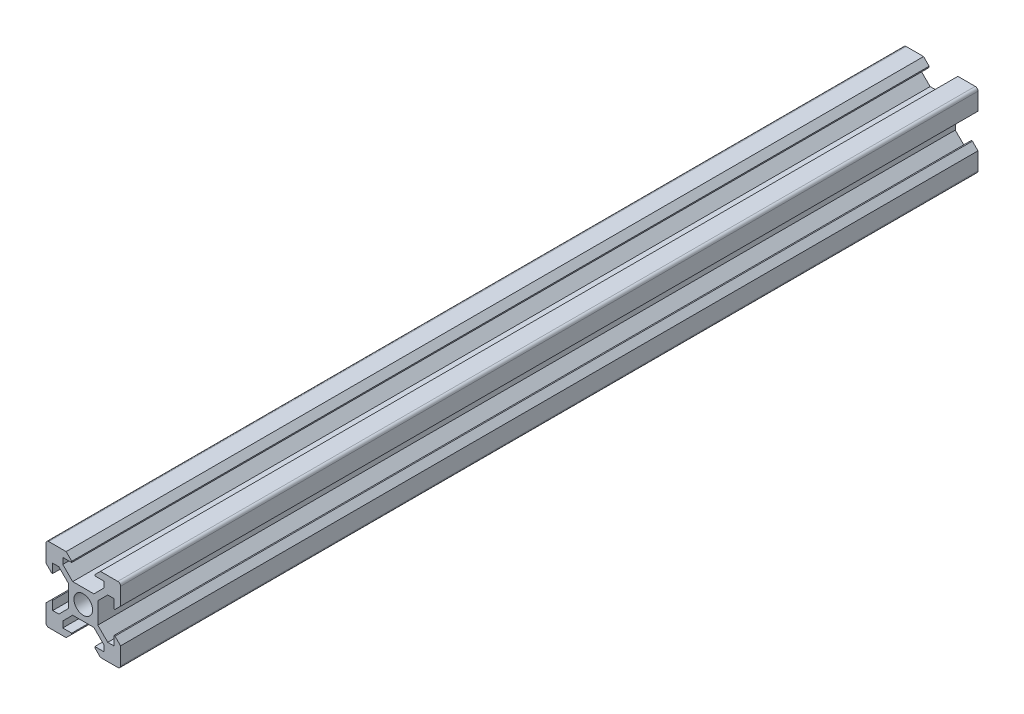
from build123d import *

# Parameters (mm, degrees)
CROQUIS1_R              = 2.5
SALIENTE_EXTRUIR1_DEPTH = 230


with BuildPart() as part:
    # Croquis1 → Saliente-Extruir1 (new body)
    with BuildSketch(Plane.XY):
        with BuildLine():
            Line((-4.6, 10), (-3.1, 8.5))
            Line((-3.1, 8.5), (-3.1, 8.2))
            Line((-3.1, 8.2), (-5.5, 8.2))
            Line((-5.5, 8.2), (-5.5, 6.560660172))
            Line((-5.5, 6.560660172), (-2.84, 3.900660172))
            Line((-2.84, 3.900660172), (0, 3.900660172))
            Line((0, 3.900660172), (2.84, 3.900660172))
            Line((2.84, 3.900660172), (5.5, 6.560660172))
            Line((5.5, 6.560660172), (5.5, 8.2))
            Line((5.5, 8.2), (3.1, 8.2))
            Line((3.1, 8.2), (3.1, 8.5))
            Line((3.1, 8.5), (4.6, 10))
            Line((4.6, 10), (9.25, 10))
            ThreePointArc((9.25, 10), (9.780330086, 9.780330086), (10, 9.25))
            Line((10, 9.25), (10, 4.6))
            Line((10, 4.6), (8.5, 3.1))
            Line((8.5, 3.1), (8.2, 3.1))
            Line((8.2, 3.1), (8.2, 5.5))
            Line((8.2, 5.5), (6.560660172, 5.5))
            Line((6.560660172, 5.5), (3.900660172, 2.84))
            Line((3.900660172, 2.84), (3.900660172, 0))
            Line((3.900660172, 0), (3.900660172, -2.84))
            Line((3.900660172, -2.84), (6.560660172, -5.5))
            Line((6.560660172, -5.5), (8.2, -5.5))
            Line((8.2, -5.5), (8.2, -3.1))
            Line((8.2, -3.1), (8.5, -3.1))
            Line((8.5, -3.1), (10, -4.6))
            Line((10, -4.6), (10, -9.25))
            ThreePointArc((10, -9.25), (9.780330086, -9.780330086), (9.25, -10))
            Line((9.25, -10), (4.6, -10))
            Line((4.6, -10), (3.1, -8.5))
            Line((3.1, -8.5), (3.1, -8.2))
            Line((3.1, -8.2), (5.5, -8.2))
            Line((5.5, -8.2), (5.5, -6.560660172))
            Line((5.5, -6.560660172), (2.84, -3.900660172))
            Line((2.84, -3.900660172), (0, -3.900660172))
            Line((0, -3.900660172), (-2.84, -3.900660172))
            Line((-2.84, -3.900660172), (-5.5, -6.560660172))
            Line((-5.5, -6.560660172), (-5.5, -8.2))
            Line((-5.5, -8.2), (-3.1, -8.2))
            Line((-3.1, -8.2), (-3.1, -8.5))
            Line((-3.1, -8.5), (-4.6, -10))
            Line((-4.6, -10), (-9.25, -10))
            ThreePointArc((-9.25, -10), (-9.780330086, -9.780330086), (-10, -9.25))
            Line((-10, -9.25), (-10, -4.6))
            Line((-10, -4.6), (-8.5, -3.1))
            Line((-8.5, -3.1), (-8.2, -3.1))
            Line((-8.2, -3.1), (-8.2, -5.5))
            Line((-8.2, -5.5), (-6.560660172, -5.5))
            Line((-6.560660172, -5.5), (-3.900660172, -2.84))
            Line((-3.900660172, -2.84), (-3.900660172, 0))
            Line((-3.900660172, 0), (-3.900660172, 2.84))
            Line((-3.900660172, 2.84), (-6.560660172, 5.5))
            Line((-6.560660172, 5.5), (-8.2, 5.5))
            Line((-8.2, 5.5), (-8.2, 3.1))
            Line((-8.2, 3.1), (-8.5, 3.1))
            Line((-8.5, 3.1), (-10, 4.6))
            Line((-10, 4.6), (-10, 9.25))
            ThreePointArc((-10, 9.25), (-9.780330086, 9.780330086), (-9.25, 10))
            Line((-9.25, 10), (-4.6, 10))
        make_face()
        Circle(CROQUIS1_R, mode=Mode.SUBTRACT)
    extrude(amount=SALIENTE_EXTRUIR1_DEPTH)


solid = part.part
